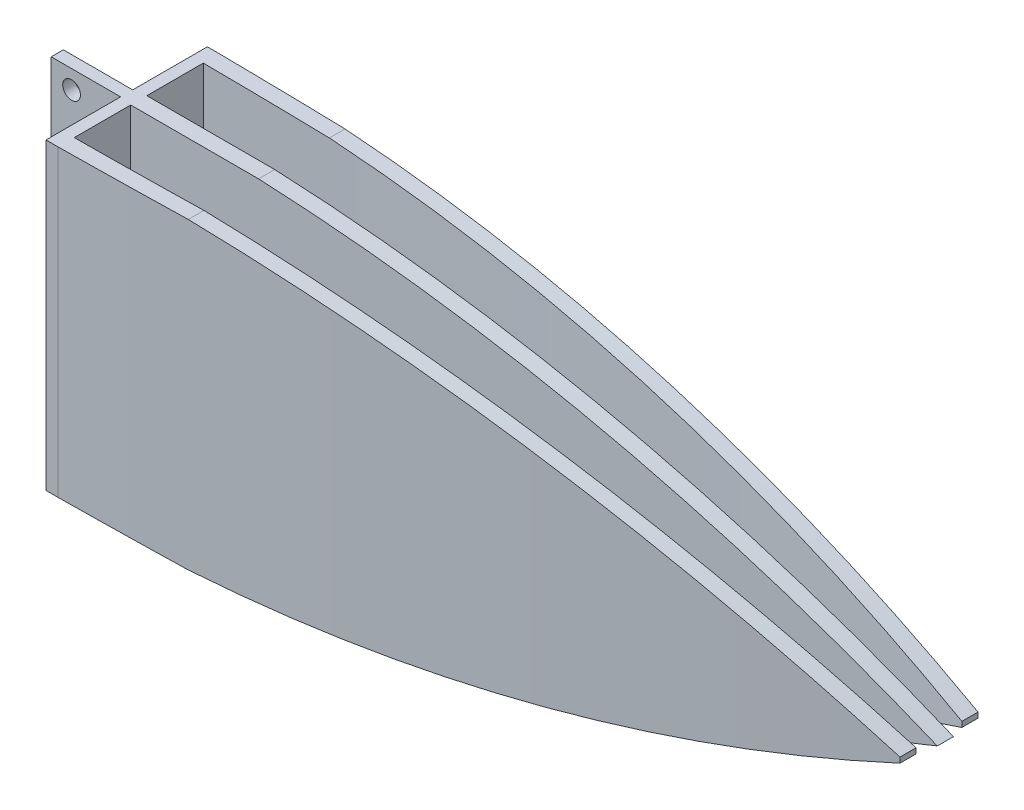
from build123d import *

# Parameters (mm, degrees)
EXTRUDE_1_DEPTH          = 0.75
EXTRUDE_1_DEPTH_BACK     = 0.75
SKETCH_1_W               = 10
SKETCH_1_H               = 38
SKETCH_1_R               = 1.1
SKETCH_3_W               = 20
SKETCH_3_H               = 38.036879249
EXTRUDE_2_DEPTH          = 1.5
EXTRUDE_3_DEPTH          = 1
EXTRUDE_3_DEPTH_BACK     = 1
EXTRUDE_4_DEPTH          = 38
CUT_EXTRUDE_1_DEPTH      = 10
CUT_EXTRUDE_1_DEPTH_BACK = 20
CUT_EXTRUDE_4_DEPTH      = 0.2
CUT_EXTRUDE_4_DEPTH_BACK = 0.2
SKETCH_10_W              = 112.497058814
SKETCH_10_H              = 20.543414641
CUT_EXTRUDE_5_DEPTH      = 0.2
CUT_EXTRUDE_5_DEPTH_BACK = 0.2
SKETCH_11_W              = 104.514605189
SKETCH_11_H              = 21.657747512


with BuildPart() as part:
    # 草圖1 → 填料-伸長1 (new, two sides: drawn at the far end of the back side and taken through both)
    with BuildSketch(Plane.XY.offset(-EXTRUDE_1_DEPTH_BACK)):
        with Locations((-4.101832994, 0.735234216)):
            Rectangle(SKETCH_1_W, SKETCH_1_H)
        with Locations((-6.601832994, -15.764765784)):
            Circle(SKETCH_1_R, mode=Mode.SUBTRACT)
        with Locations((-6.578411405, 17.235234216)):
            Circle(SKETCH_1_R, mode=Mode.SUBTRACT)
    extrude(amount=EXTRUDE_1_DEPTH + EXTRUDE_1_DEPTH_BACK)

    # 草圖3 → 填料-伸長2 (add)
    with BuildSketch(Plane(origin=(-0.5, 0, 0), x_dir=(0, 0, -1), z_dir=(1, 0, 0))):
        with Locations((0, 0.716794592)):
            Rectangle(SKETCH_3_W, SKETCH_3_H)
    extrude(amount=EXTRUDE_2_DEPTH)

    # 草圖4 → 填料-伸長3 (add, two sides: drawn at the far end of the back side and taken through both)
    with BuildSketch(Plane.XY.offset(-EXTRUDE_3_DEPTH_BACK)):
        with BuildLine():
            Line((1, 19.735234216), (1, -18.298860138))
            ThreePointArc((1, -18.298860138), (51.989546932, -13.993809638), (101, 0.718187039))
            ThreePointArc((101, 0.718187039), (51.989546932, 15.430183716), (1, 19.735234216))
        make_face()
    extrude(amount=EXTRUDE_3_DEPTH + EXTRUDE_3_DEPTH_BACK)

    # 草圖5 → 填料-伸長4 (add)
    with BuildSketch(Plane(origin=(0, 19.735234216, 0), x_dir=(1, 0, 0), z_dir=(0, 1, 0))):
        with BuildLine():
            Line((1, -8), (1, -10))
            ThreePointArc((1, -10), (50.655745388, -8.426256946), (100.20651497, -4.835859882))
            Line((100.20651497, -4.835859882), (100.20651497, -2.835859882))
            ThreePointArc((100.20651497, -2.835859882), (50.661805416, -6.542674054), (1, -8))
        make_face()
        with BuildLine():
            Line((100.20651497, 2.835859882), (100.20651497, 4.835859882))
            ThreePointArc((100.20651497, 4.835859882), (50.655745388, 8.426256946), (1, 10))
            Line((1, 10), (1, 8))
            ThreePointArc((1, 8), (50.661805416, 6.542674054), (100.20651497, 2.835859882))
        make_face()
    extrude(amount=-EXTRUDE_4_DEPTH)

    # 草圖8 → 除料-伸長1 (cut, two sides: drawn at the far end of the back side and taken through both)
    with BuildSketch(Plane.XY.offset(10).offset(-CUT_EXTRUDE_1_DEPTH_BACK)):
        with BuildLine():
            Line((13.103688801, -18.23809131), (101, -18.264765784))
            Line((101, -18.264765784), (101, 0.718187039))
            ThreePointArc((101, 0.718187039), (57.921072507, -12.790381672), (13.103688801, -18.23809131))
        make_face()
        with BuildLine():
            ThreePointArc((13.103688801, 19.674465387), (57.921072507, 14.22675575), (101, 0.718187039))
            Line((101, 0.718187039), (101, 19.701139862))
            Line((101, 19.701139862), (13.103688801, 19.674465387))
        make_face()
    extrude(amount=CUT_EXTRUDE_1_DEPTH + CUT_EXTRUDE_1_DEPTH_BACK, mode=Mode.SUBTRACT)

    # 草圖10 → 除料-伸長4 (cut, two sides: drawn at the far end of the back side and taken through both)
    with BuildSketch(Plane(origin=(0, 19.735234216, 0), x_dir=(1, 0, 0), z_dir=(0, 1, 0)).offset(-CUT_EXTRUDE_4_DEPTH_BACK)):
        with Locations((46.49437126, 0.271707321)):
            Rectangle(SKETCH_10_W, SKETCH_10_H)
    extrude(amount=CUT_EXTRUDE_4_DEPTH + CUT_EXTRUDE_4_DEPTH_BACK, mode=Mode.SUBTRACT)

    # 草圖11 → 除料-伸長5 (cut, two sides: drawn at the far end of the back side and taken through both)
    with BuildSketch(Plane(origin=(0, -18.301645033, 0), x_dir=(-1, 0, 0), z_dir=(0, -1, 0)).offset(-CUT_EXTRUDE_5_DEPTH_BACK)):
        with Locations((-51.541283716, 0.828873756)):
            Rectangle(SKETCH_11_W, SKETCH_11_H)
    extrude(amount=CUT_EXTRUDE_5_DEPTH + CUT_EXTRUDE_5_DEPTH_BACK, mode=Mode.SUBTRACT)


solid = part.part
